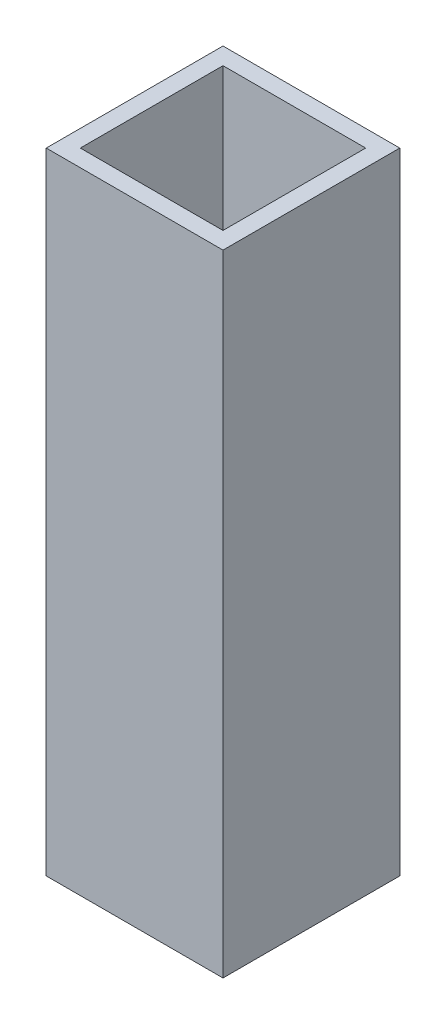
from build123d import *

# Parameters (mm, degrees)
SKETCH1_W           = 12.45
SKETCH1_H           = 12.45
BOSS_EXTRUDE1_DEPTH = 44.4
SHELL1_T            = -1.2


with BuildPart() as part:
    # Sketch1 → Boss-Extrude1 (new body)
    with BuildSketch(Plane(origin=(0, 0, 0), x_dir=(1, 0, 0), z_dir=(0, 1, 0))):
        Rectangle(SKETCH1_W, SKETCH1_H)
    extrude(amount=BOSS_EXTRUDE1_DEPTH)

    # Shell1
    shell1_openings = [part.faces().sort_by_distance(p)[0] for p in [
        (0, 44.4, 0),
    ]]
    offset(amount=SHELL1_T, openings=shell1_openings, kind=Kind.INTERSECTION)


solid = part.part
